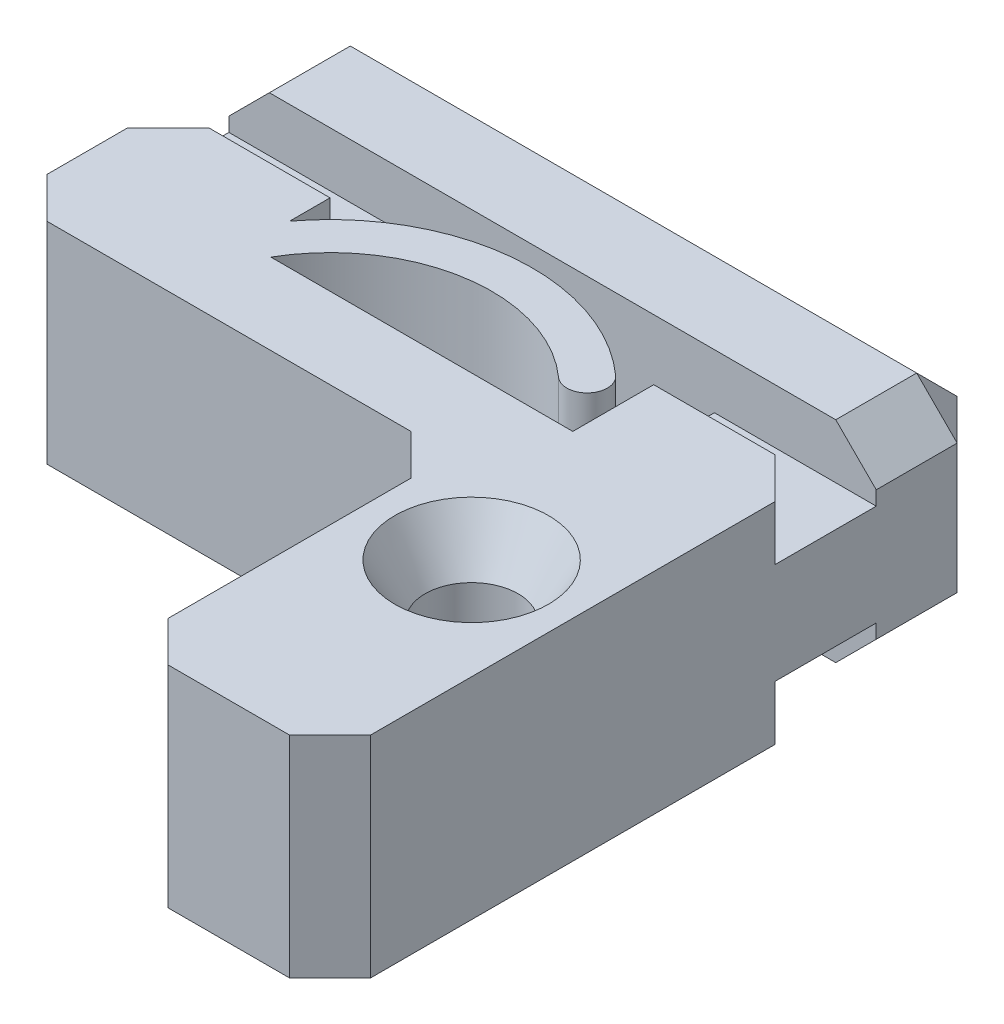
from build123d import *

# Parameters (mm, degrees)
SKETCH1_R             = 1.15
BOSS_EXTRUDE1_DEPTH   = 2.6
BOSS_EXTRUDE2_DEPTH   = 4
SKETCH3_W             = 3
SKETCH3_H             = 5.2
BOSS_EXTRUDE3_DEPTH   = 8
BOSS_EXTRUDE4_DEPTH   = 2.6
CHAMFER1_SIZE         = 1
CHAMFER2_SIZE         = 0.75
CHAMFER2_SIZE2        = 1.299038106
CHAMFER2_PART_2_SIZE  = 0.75
CHAMFER2_PART_2_SIZE2 = 1.299038106


with BuildPart() as part:
    # Sketch1 → Boss-Extrude1 (new body, symmetric)
    with BuildSketch(Plane(origin=(0, 0, 0), x_dir=(1, 0, 0), z_dir=(0, 1, 0))):
        Polygon((4, 0), (8, 0), (8, -12), (3, -12), (3, -4), (-8, -4), (-8, 0), (-4, 0), (-4, -2), (4, -2), align=None)
        with Locations((5.5, -6)):
            Circle(SKETCH1_R, mode=Mode.SUBTRACT)
    extrude(amount=BOSS_EXTRUDE1_DEPTH, both=True)

    # Sketch2 → Boss-Extrude2 (add)
    with BuildSketch(Plane.ZY.offset(8)):
        Polygon((-1.5, -1.25), (-1.5, -2.6), (-4.5, -2.6), (-4.5, 2.6), (-1.5, 2.6), (-1.5, 1.25), (0, 1.25), (0, -1.25), align=None)
    boss_extrude2 = extrude(amount=-BOSS_EXTRUDE2_DEPTH)

    # Mirror1: Boss-Extrude2 across plane
    add(boss_extrude2.mirror(Plane(origin=(0, 0, 0), x_dir=(0, 0, 1), z_dir=(1, 0, 0))))

    # Sketch3 → Boss-Extrude3 (add)
    with BuildSketch(Plane(origin=(-4, 0, 0), x_dir=(0, 0, -1), z_dir=(1, 0, 0))):
        with Locations((3, 0)):
            Rectangle(SKETCH3_W, SKETCH3_H)
    extrude(amount=BOSS_EXTRUDE3_DEPTH)

    # Sketch4 → Boss-Extrude4 (add, symmetric)
    with BuildSketch(Plane(origin=(0, 0, 0), x_dir=(1, 0, 0), z_dir=(0, 1, 0))):
        with BuildLine():
            Line((-4, -1), (-4, -2))
            Line((-4, -2), (-3.464101615, -2))
            ThreePointArc((-3.464101615, -2), (-0.63227674, -0.050287843), (2.666666667, -1.01857603))
            ThreePointArc((2.666666667, -1.01857603), (3.372677996, -0.979231367), (3.333333333, -0.273220038))
            ThreePointArc((3.333333333, -0.273220038), (-0.493116, 0.975624243), (-4, -1))
        make_face()
    extrude(amount=BOSS_EXTRUDE4_DEPTH, both=True)

    # Chamfer1
    chamfer1_edges = [part.edges().sort_by_distance(p)[0] for p in [
        (-8, 1.925, 0),
        (8, 1.925, 0),
        (8, 0, 12),
        (3, 0, 12),
        (3, 0, 4),
        (-8, 0, 4),
        (-8, -1.925, 0),
        (0, -2.6, -4.5),
        (0, 2.6, -4.5),
        (-8, 0, -4.5),
        (-8, -2.6, -3),
        (-8, 2.6, -3),
        (8, -1.925, 0),
        (8, 0, -4.5),
        (8, -2.6, -3),
        (8, 2.6, -3),
    ]]
    chamfer(chamfer1_edges, length=CHAMFER1_SIZE)

    # Chamfer2
    chamfer2_edges = [part.edges().sort_by_distance(p)[0] for p in [
        (4.35, -2.6, 6),
    ]]
    chamfer2_side = [part.faces().sort_by_distance(p)[0] for p in [
        (5.5, -2.6, 0.206155281),
    ]]
    chamfer(chamfer2_edges, length=CHAMFER2_SIZE, length2=CHAMFER2_SIZE2, reference=chamfer2_side[0])

    # Chamfer2 part 2
    chamfer2_part_2_edges = [part.edges().sort_by_distance(p)[0] for p in [
        (4.35, 2.6, 6),
    ]]
    chamfer2_part_2_side = [part.faces().sort_by_distance(p)[0] for p in [
        (5.5, 2.6, 0.206155281),
    ]]
    chamfer(chamfer2_part_2_edges, length=CHAMFER2_PART_2_SIZE, length2=CHAMFER2_PART_2_SIZE2, reference=chamfer2_part_2_side[0])


solid = part.part
